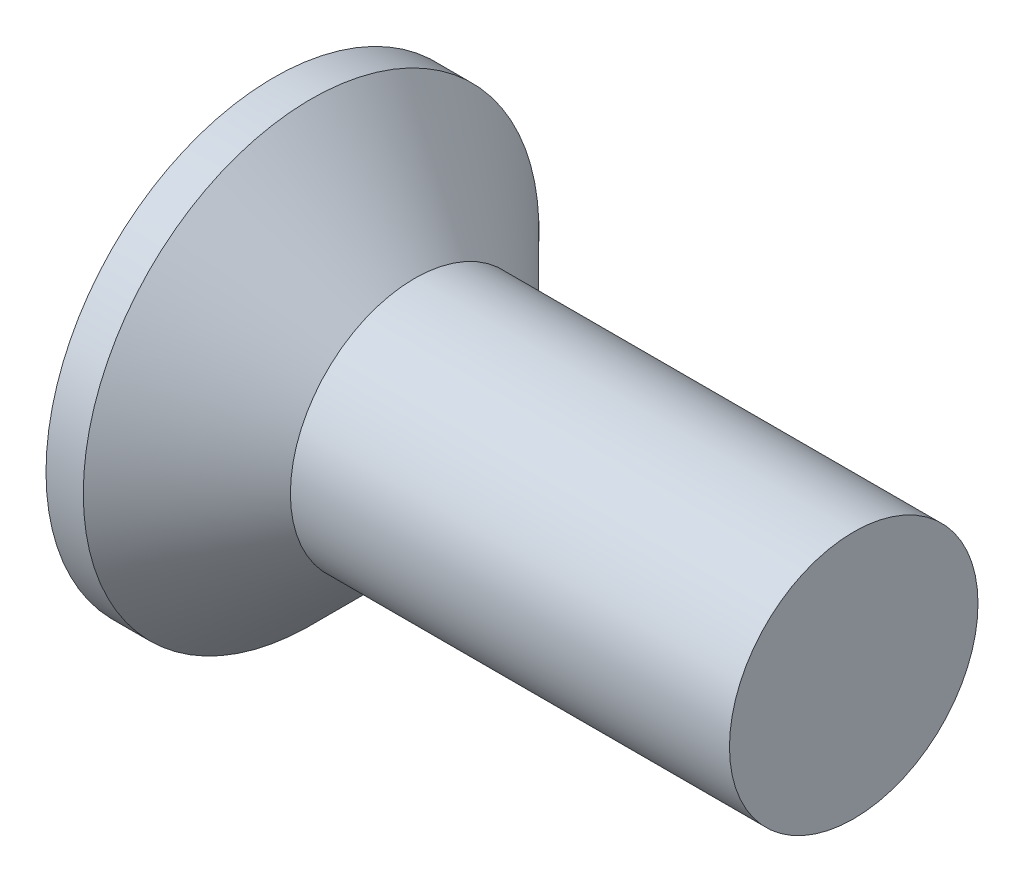
from build123d import *

# Parameters (mm, degrees)
SKETCH3_W         = 0.79
SKETCH3_H         = 3.1
SKETCH4_W         = 0.395
SKETCH4_H         = 0.395
CIRPATTERN1_COUNT = 2
CIRPATTERN1_ANGLE = 90


with BuildPart() as part:
    # BodySke → Base-Revolve (revolve)
    with BuildSketch(Plane.XY):
        Polygon((0, 0), (0, 2.75), (0.45, 2.75), (1.7, 1.5), (7, 1.5), (7, 0), align=None)
    revolve(axis=Axis((-6.35, 0, 0), (1, 0, 0)))

    # Sketch3 → Cross section 0
    with BuildSketch(Plane.ZY):
        Rectangle(SKETCH3_W, SKETCH3_H)
    # Sketch4 → Cross section 1
    with BuildSketch(Plane.ZY.offset(-2.08)):
        Rectangle(SKETCH4_W, SKETCH4_H)
    cross = loft(mode=Mode.SUBTRACT)

    # CirPattern1: Cross ×2 about axis
    cirpattern1_axis = Axis((0, 0, 0), (1, 0, 0))
    for i in range(1, CIRPATTERN1_COUNT):
        add(cross.rotate(cirpattern1_axis, i * CIRPATTERN1_ANGLE / (CIRPATTERN1_COUNT - 1)), mode=Mode.SUBTRACT)


solid = part.part
